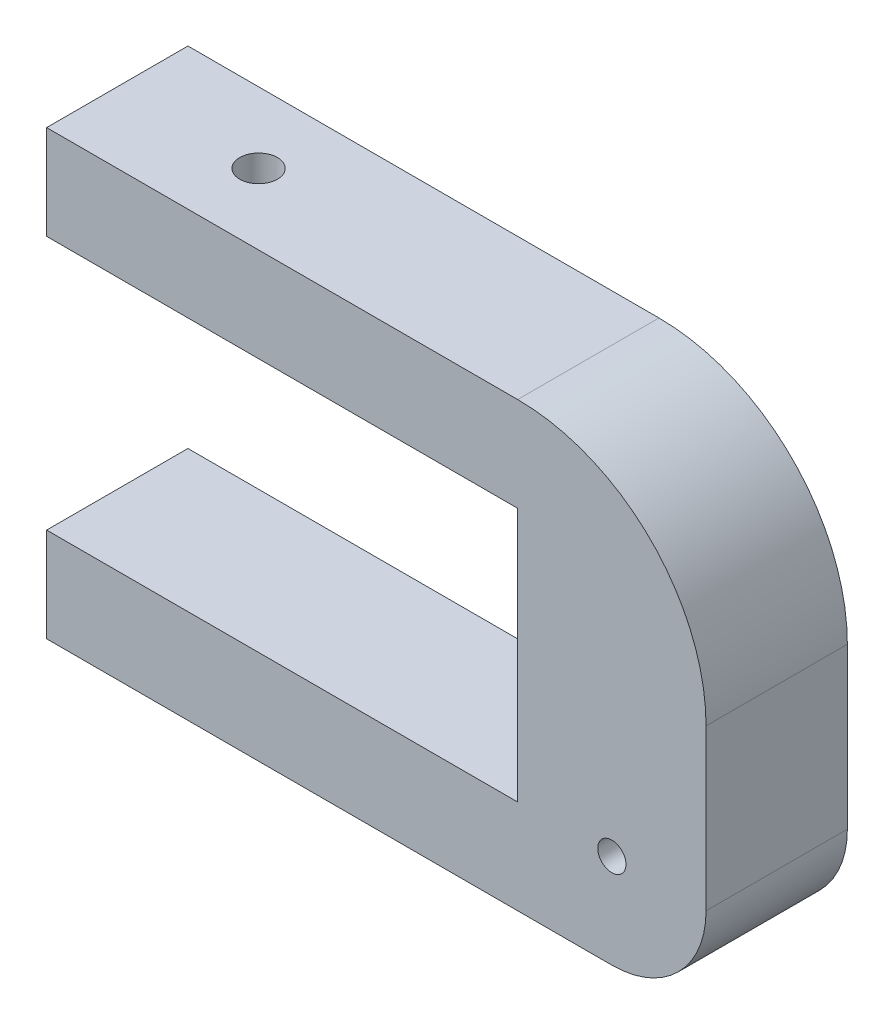
from build123d import *

# Parameters (mm, degrees)
ESQUISSE1_R             = 1.5
BOSS_EXTRU_1_DEPTH      = 15
ESQUISSE3_R             = 5
ENL_V_MAT_EXTRU_1_DEPTH = 2
ESQUISSE4_R             = 2
ENL_V_MAT_EXTRU_2_DEPTH = 9
ENL_V_MAT_EXTRU_3_DEPTH = 2.5


with BuildPart() as part:
    # Esquisse1 → Boss.-Extru.1 (new body)
    with BuildSketch(Plane.XY):
        with BuildLine():
            Line((0, 0), (50, 0))
            ThreePointArc((50, 0), (64.142135624, -5.857864376), (70, -20))
            Line((70, -20), (70, -37))
            ThreePointArc((70, -37), (67.071067812, -44.071067812), (60, -47))
            Line((60, -47), (0, -47))
            Line((0, -47), (0, -37))
            Line((0, -37), (50, -37))
            Line((50, -37), (50, -10))
            Line((50, -10), (0, -10))
            Line((0, -10), (0, 0))
        make_face()
        with Locations((60, -37)):
            Circle(ESQUISSE1_R, mode=Mode.SUBTRACT)
    extrude(amount=BOSS_EXTRU_1_DEPTH)

    # Esquisse3 → Enlèv. mat.-Extru.1 (cut)
    with BuildSketch(Plane.XZ.offset(10)):
        with Locations((15, 7.5)):
            Circle(ESQUISSE3_R)
    extrude(amount=-ENL_V_MAT_EXTRU_1_DEPTH, mode=Mode.SUBTRACT)

    # Esquisse4 → Enlèv. mat.-Extru.2 (cut, through all)
    with BuildSketch(Plane(origin=(0, -8, 0), x_dir=(-1, 0, 0), z_dir=(0, -1, 0))):
        with Locations((-15, -7.5)):
            Circle(ESQUISSE4_R)
    extrude(amount=-ENL_V_MAT_EXTRU_2_DEPTH, mode=Mode.SUBTRACT)

    # Esquisse5 → Enlèv. mat.-Extru.3 (cut)
    with BuildSketch(Plane.XZ.offset(8)):
        Polygon((12.5, 6.056624327), (12.5, 8.943375673), (15, 10.386751346), (17.5, 8.943375673), (17.5, 6.056624327), (15, 4.613248654), align=None)
    extrude(amount=-ENL_V_MAT_EXTRU_3_DEPTH, mode=Mode.SUBTRACT)


solid = part.part
